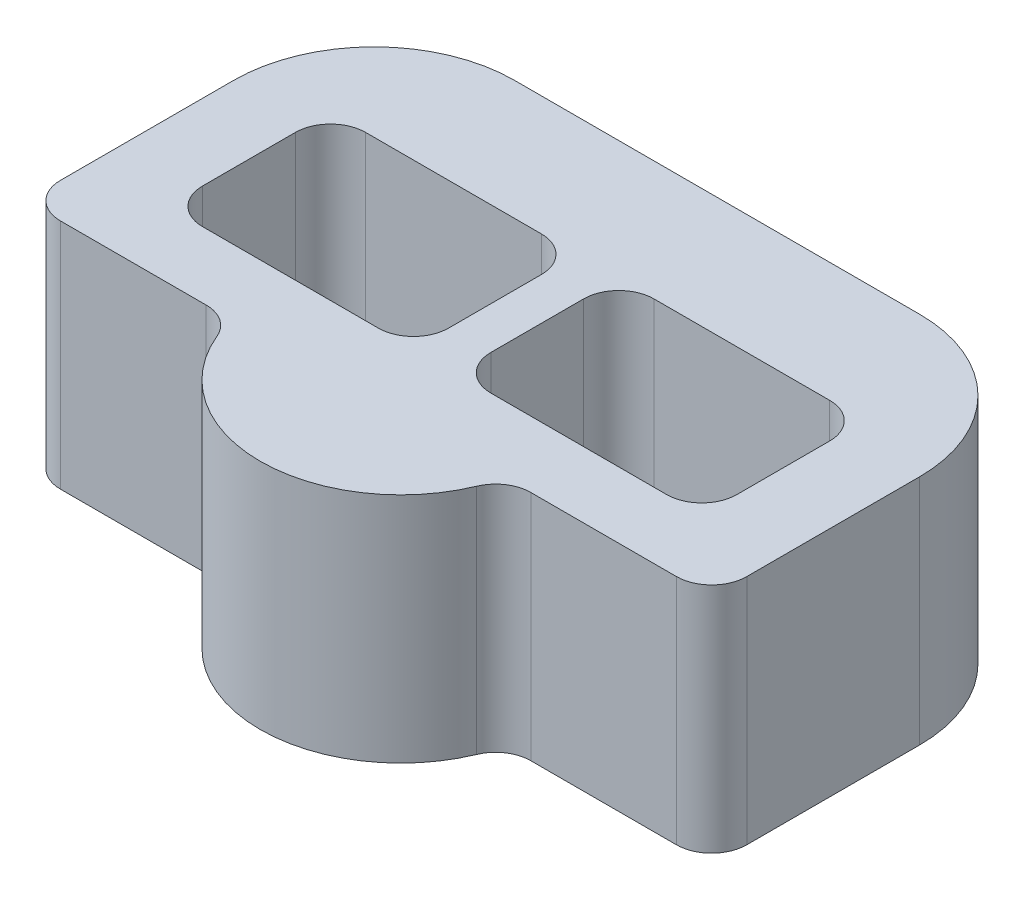
from build123d import *

# Parameters (mm, degrees)
BOSS_EXTRUDE1_DEPTH = 20.9804
CUT_EXTRUDE1_DEPTH  = 15.9004


with BuildPart() as part:
    # Sketch1 → Boss-Extrude1 (new body)
    with BuildSketch(Plane(origin=(0, 0, 0), x_dir=(1, 0, 0), z_dir=(0, 1, 0))):
        with BuildLine():
            Line((0, -8.255), (0, -23.876))
            ThreePointArc((0, -23.876), (0.92993597, -26.12106403), (3.175, -27.051))
            Line((3.175, -27.051), (16.330087154, -27.051))
            ThreePointArc((16.330087154, -27.051), (18.092140644, -27.584827438), (19.261669723, -29.0068))
            ThreePointArc((19.261669723, -29.0068), (30.988, -36.83), (42.714330277, -29.0068))
            ThreePointArc((42.714330277, -29.0068), (43.883859356, -27.584827438), (45.645912846, -27.051))
            Line((45.645912846, -27.051), (58.801, -27.051))
            ThreePointArc((58.801, -27.051), (61.04606403, -26.12106403), (61.976, -23.876))
            Line((61.976, -23.876), (61.976, -8.255))
            ThreePointArc((61.976, -8.255), (58.256256121, 0.725256121), (49.276, 4.445))
            Line((49.276, 4.445), (12.7, 4.445))
            ThreePointArc((12.7, 4.445), (3.719743879, 0.725256121), (0, -8.255))
        make_face()
        with BuildLine():
            Line((13.208, -10.541), (22.733, -10.541))
            ThreePointArc((22.733, -10.541), (25.908, -13.716), (22.733, -16.891))
            Line((22.733, -16.891), (13.208, -16.891))
            ThreePointArc((13.208, -16.891), (10.033, -13.716), (13.208, -10.541))
        make_face(mode=Mode.SUBTRACT)
        with BuildLine():
            Line((48.768, -10.541), (39.243, -10.541))
            ThreePointArc((39.243, -10.541), (36.068, -13.716), (39.243, -16.891))
            Line((39.243, -16.891), (48.768, -16.891))
            ThreePointArc((48.768, -16.891), (51.943, -13.716), (48.768, -10.541))
        make_face(mode=Mode.SUBTRACT)
    extrude(amount=BOSS_EXTRUDE1_DEPTH)

    # Sketch2 → Cut-Extrude1 (cut)
    with BuildSketch(Plane(origin=(0, 20.9804, 0), x_dir=(1, 0, 0), z_dir=(0, 1, 0))):
        with BuildLine():
            Line((6.858, -9.525), (6.858, -17.907))
            ThreePointArc((6.858, -17.907), (7.78793597, -20.15206403), (10.033, -21.082))
            Line((10.033, -21.082), (25.908, -21.082))
            ThreePointArc((25.908, -21.082), (28.15306403, -20.15206403), (29.083, -17.907))
            Line((29.083, -17.907), (29.083, -9.525))
            ThreePointArc((29.083, -9.525), (28.15306403, -7.27993597), (25.908, -6.35))
            Line((25.908, -6.35), (10.033, -6.35))
            ThreePointArc((10.033, -6.35), (7.78793597, -7.27993597), (6.858, -9.525))
        make_face()
        with BuildLine():
            Line((51.943, -6.35), (36.068, -6.35))
            ThreePointArc((36.068, -6.35), (33.82293597, -7.27993597), (32.893, -9.525))
            Line((32.893, -9.525), (32.893, -17.907))
            ThreePointArc((32.893, -17.907), (33.82293597, -20.15206403), (36.068, -21.082))
            Line((36.068, -21.082), (51.943, -21.082))
            ThreePointArc((51.943, -21.082), (54.18806403, -20.15206403), (55.118, -17.907))
            Line((55.118, -17.907), (55.118, -9.525))
            ThreePointArc((55.118, -9.525), (54.18806403, -7.27993597), (51.943, -6.35))
        make_face()
    extrude(amount=-CUT_EXTRUDE1_DEPTH, mode=Mode.SUBTRACT)


solid = part.part
